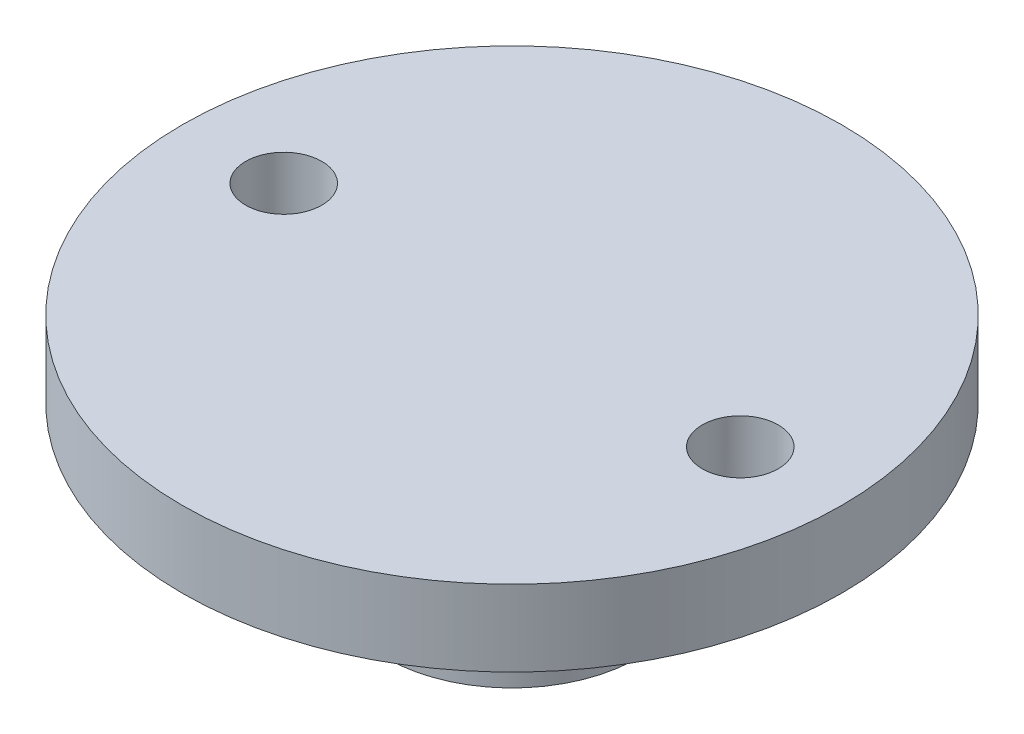
from build123d import *

# Parameters (mm, degrees)
SKETCH2_R          = 1.5
CUT_EXTRUDE1_DEPTH = 10.2


with BuildPart() as part:
    # Sketch1 → Revolve1 (revolve)
    with BuildSketch(Plane.XY):
        Polygon((13, 0), (13, -3), (5, -3), (5, -9.2), (3, -9.2), (3, -6.2), (0, -6.2), (0, 0), align=None)
    revolve(axis=Axis((0, 0, 0), (0, 1, 0)))

    # Sketch2 → Cut-Extrude1 (cut, through all)
    with BuildSketch(Plane(origin=(0, 0, 0), x_dir=(1, 0, 0), z_dir=(0, 1, 0))):
        with Locations((9, 0)):
            Circle(SKETCH2_R)
        with Locations((-9, 0)):
            Circle(SKETCH2_R)
    extrude(amount=-CUT_EXTRUDE1_DEPTH, mode=Mode.SUBTRACT)


solid = part.part
